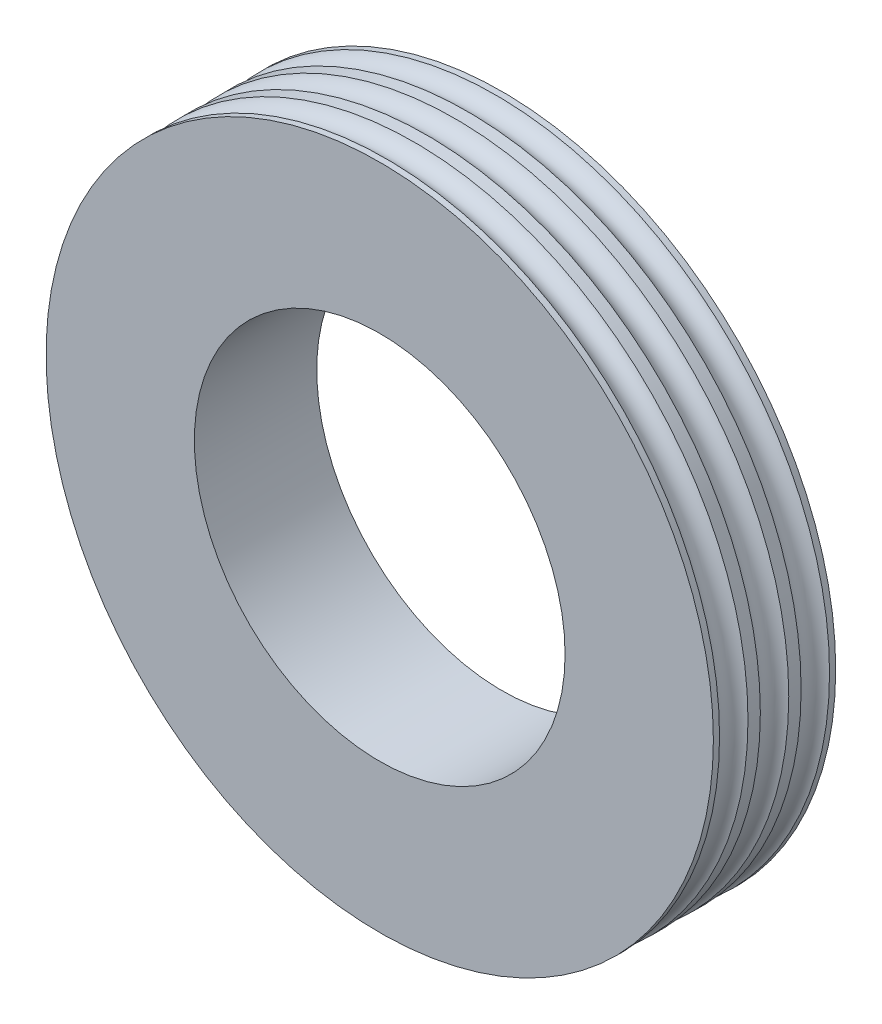
from build123d import *


with BuildPart() as part:
    # Sketch2 → Revolve1 (revolve)
    with BuildSketch(Plane(origin=(0, 0, 0), x_dir=(0, 0, -1), z_dir=(1, 0, 0))):
        with BuildLine():
            Line((-0.34, 3), (-0.34, 5.4))
            Line((-0.34, 5.4), (-0.44, 5.4))
            ThreePointArc((-0.44, 5.4), (-0.67, 5.249201276), (-0.9, 5.4))
            Line((-0.9, 5.4), (-1, 5.4))
            Line((-1, 5.4), (-1, 3))
            Line((-1, 3), (-0.34, 3))
        make_face()
    revolve1 = revolve(axis=Axis((0, 0, 3.014677367), (0, 0, -1)))

    # Mirror2: Revolve1 across plane
    add(revolve1.mirror(Plane(origin=(0, 0, 0.34), x_dir=(1, 0, 0), z_dir=(0, 0, -1))))

    # Mirror3: Revolve1 across plane
    add(revolve1.mirror(Plane.XY.offset(1)))


solid = part.part
